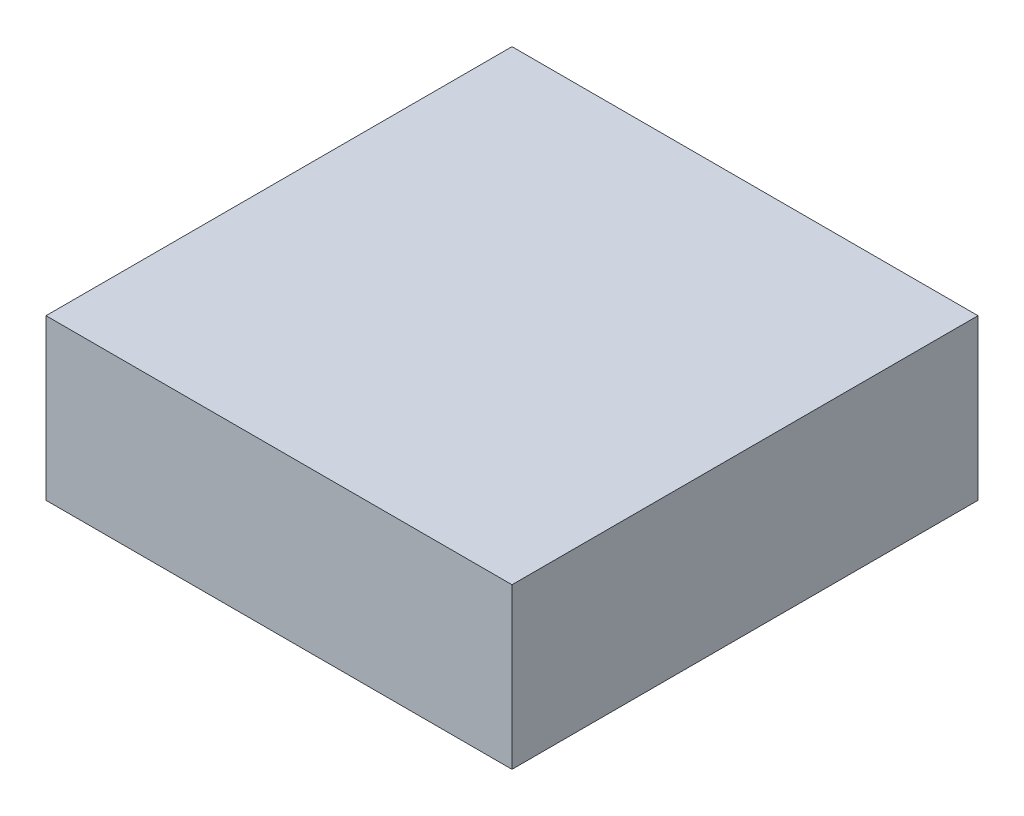
from build123d import *

# Parameters (mm, degrees)
SKETCH1_W           = 102
SKETCH1_H           = 102
BOSS_EXTRUDE1_DEPTH = 35


with BuildPart() as part:
    # Sketch1 → Boss-Extrude1 (new body)
    with BuildSketch(Plane(origin=(0, 0, 0), x_dir=(1, 0, 0), z_dir=(0, 1, 0))):
        with Locations((51, 51)):
            Rectangle(SKETCH1_W, SKETCH1_H)
    extrude(amount=BOSS_EXTRUDE1_DEPTH)


solid = part.part
